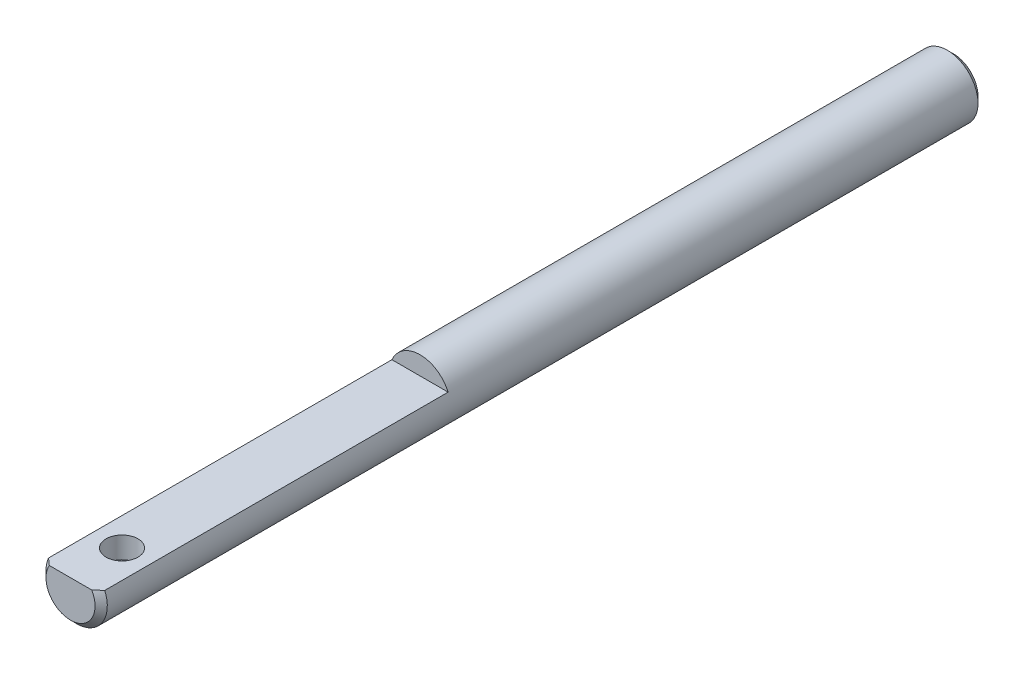
from build123d import *

# Parameters (mm, degrees)
SKETCH1_R          = 3.175
EXTRUDE1_DEPTH     = 45.72
CHAMFER1_SIZE      = 0.635
EXTRUDE7_DEPTH     = 37.195
SKETCH14_R         = 1.651
CUT_EXTRUDE1_DEPTH = 2.2225


with BuildPart() as part:
    # Sketch1 → Extrude1 (new body, symmetric)
    with BuildSketch(Plane.XY):
        Circle(SKETCH1_R)
    extrude(amount=EXTRUDE1_DEPTH, both=True)

    # Chamfer1
    chamfer1_edges = [part.edges().sort_by_distance(p)[0] for p in [
        (-3.175, 0, -45.72),
        (-3.175, 0, 45.72),
    ]]
    chamfer(chamfer1_edges, length=CHAMFER1_SIZE)

    # Sketch13 → Extrude7 (cut, through all)
    with BuildSketch(Plane.XY.offset(9.525)):
        with BuildLine():
            Line((-2.909935566, 1.27), (2.909935566, 1.27))
            ThreePointArc((2.909935566, 1.27), (0, 3.175), (-2.909935566, 1.27))
        make_face()
    extrude(amount=EXTRUDE7_DEPTH, mode=Mode.SUBTRACT)

    # Sketch14 → Cut-Extrude1 (cut)
    with BuildSketch(Plane(origin=(0, 1.27, 0), x_dir=(1, 0, 0), z_dir=(0, 1, 0))):
        with Locations((0, -40.386)):
            Circle(SKETCH14_R)
    extrude(amount=-CUT_EXTRUDE1_DEPTH, mode=Mode.SUBTRACT)


solid = part.part
